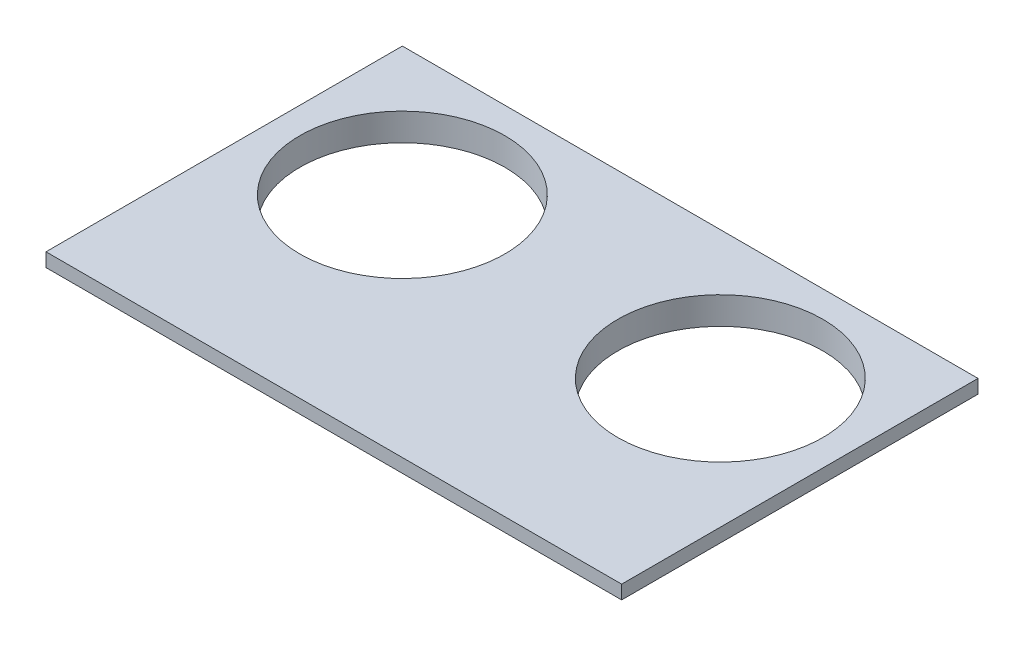
from build123d import *

# Parameters (mm, degrees)
SKETCH1_W           = 105
SKETCH1_H           = 65
BOSS_EXTRUDE1_DEPTH = 5
SKETCH2_W           = 105
SKETCH2_H           = 65
SKETCH2_W_2         = 100
SKETCH2_H_2         = 60
CUT_EXTRUDE1_DEPTH  = 2.5
SKETCH3_R           = 18.7
CUT_EXTRUDE2_DEPTH  = 50


with BuildPart() as part:
    # Sketch1 → Boss-Extrude1 (new body)
    with BuildSketch(Plane(origin=(0, 0, 0), x_dir=(1, 0, 0), z_dir=(0, 1, 0))):
        Rectangle(SKETCH1_W, SKETCH1_H)
    extrude(amount=BOSS_EXTRUDE1_DEPTH)

    # Sketch2 → Cut-Extrude1 (cut)
    with BuildSketch(Plane.XZ):
        Rectangle(SKETCH2_W, SKETCH2_H)
        Rectangle(SKETCH2_W_2, SKETCH2_H_2, mode=Mode.SUBTRACT)
    extrude(amount=-CUT_EXTRUDE1_DEPTH, mode=Mode.SUBTRACT)

    # Sketch3 → Cut-Extrude2 (cut)
    with BuildSketch(Plane(origin=(0, 5, 0), x_dir=(1, 0, 0), z_dir=(0, 1, 0))):
        with Locations((-29, 9)):
            Circle(SKETCH3_R)
        with Locations((29, 9)):
            Circle(SKETCH3_R)
    extrude(amount=-CUT_EXTRUDE2_DEPTH, mode=Mode.SUBTRACT)


solid = part.part
